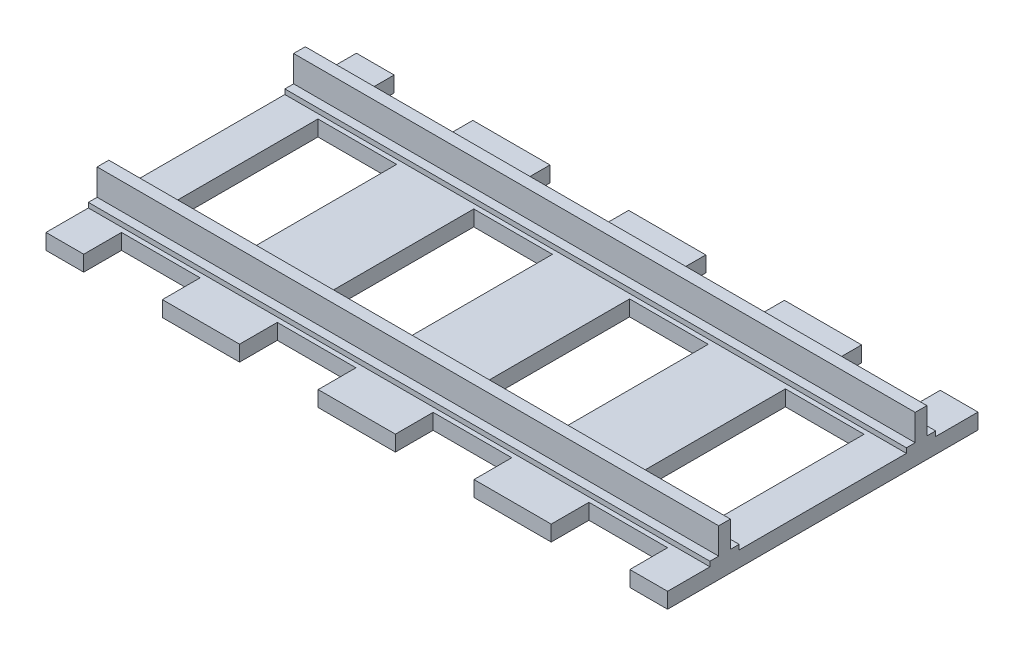
from build123d import *

# Parameters (mm, degrees)
SKETCH1_W           = 7.75
SKETCH1_H           = 32.45
SKETCH1_H_2         = 7.9
SKETCH1_H_3         = 7.75
SKETCH1_W_2         = 16.15
SKETCH1_W_3         = 15.85
BOSS_EXTRUDE1_DEPTH = 3.2
SKETCH2_W           = 127.65
SKETCH2_H           = 6
BOSS_EXTRUDE2_DEPTH = 1
SKETCH3_W           = 127.65
SKETCH3_H           = 2.4
BOSS_EXTRUDE3_DEPTH = 5.4


with BuildPart() as part:
    # Sketch1 → Boss-Extrude1 (new body)
    with BuildSketch(Plane(origin=(0, 0, 0), x_dir=(1, 0, 0), z_dir=(0, 1, 0))):
        with Locations((-59.95, 0)):
            Rectangle(SKETCH1_W, SKETCH1_H)
        with Locations((-59.95, 20.175)):
            Rectangle(SKETCH1_W, SKETCH1_H_2)
        with Locations((-59.95, 28)):
            Rectangle(SKETCH1_W, SKETCH1_H_3)
        with Locations((-59.95, -20.175)):
            Rectangle(SKETCH1_W, SKETCH1_H_2)
        with Locations((-59.95, -28)):
            Rectangle(SKETCH1_W, SKETCH1_H_3)
        with Locations((-48, 20.175)):
            Rectangle(SKETCH1_W_2, SKETCH1_H_2)
        with Locations((-48, -20.175)):
            Rectangle(SKETCH1_W_2, SKETCH1_H_2)
        with Locations((-32, -28)):
            Rectangle(SKETCH1_W_3, SKETCH1_H_3)
        with Locations((-32, -20.175)):
            Rectangle(SKETCH1_W_3, SKETCH1_H_2)
        with Locations((-32, 0)):
            Rectangle(SKETCH1_W_3, SKETCH1_H)
        with Locations((-32, 20.175)):
            Rectangle(SKETCH1_W_3, SKETCH1_H_2)
        with Locations((-32, 28)):
            Rectangle(SKETCH1_W_3, SKETCH1_H_3)
        with Locations((-16, 20.175)):
            Rectangle(SKETCH1_W_2, SKETCH1_H_2)
        with Locations((-16, -20.175)):
            Rectangle(SKETCH1_W_2, SKETCH1_H_2)
        with Locations((0, -20.175)):
            Rectangle(SKETCH1_W_3, SKETCH1_H_2)
        with Locations((0, -28)):
            Rectangle(SKETCH1_W_3, SKETCH1_H_3)
        with Locations((0, 20.175)):
            Rectangle(SKETCH1_W_3, SKETCH1_H_2)
        Rectangle(SKETCH1_W_3, SKETCH1_H)
        with Locations((0, 28)):
            Rectangle(SKETCH1_W_3, SKETCH1_H_3)
        with Locations((32, 28)):
            Rectangle(SKETCH1_W_3, SKETCH1_H_3)
        with Locations((32, 20.175)):
            Rectangle(SKETCH1_W_3, SKETCH1_H_2)
        with Locations((32, 0)):
            Rectangle(SKETCH1_W_3, SKETCH1_H)
        with Locations((32, -20.175)):
            Rectangle(SKETCH1_W_3, SKETCH1_H_2)
        with Locations((32, -28)):
            Rectangle(SKETCH1_W_3, SKETCH1_H_3)
        with Locations((16, 20.175)):
            Rectangle(SKETCH1_W_2, SKETCH1_H_2)
        with Locations((16, -20.175)):
            Rectangle(SKETCH1_W_2, SKETCH1_H_2)
        with Locations((48, -20.175)):
            Rectangle(SKETCH1_W_2, SKETCH1_H_2)
        with Locations((48, 20.175)):
            Rectangle(SKETCH1_W_2, SKETCH1_H_2)
        with Locations((59.95, 28)):
            Rectangle(SKETCH1_W, SKETCH1_H_3)
        with Locations((59.95, 20.175)):
            Rectangle(SKETCH1_W, SKETCH1_H_2)
        with Locations((59.95, 0)):
            Rectangle(SKETCH1_W, SKETCH1_H)
        with Locations((59.95, -20.175)):
            Rectangle(SKETCH1_W, SKETCH1_H_2)
        with Locations((59.95, -28)):
            Rectangle(SKETCH1_W, SKETCH1_H_3)
    extrude(amount=BOSS_EXTRUDE1_DEPTH)

    # Sketch2 → Boss-Extrude2 (add)
    with BuildSketch(Plane(origin=(0, 3.2, 0), x_dir=(1, 0, 0), z_dir=(0, 1, 0))):
        with Locations((0, -20.175)):
            Rectangle(SKETCH2_W, SKETCH2_H)
        with Locations((0, 20.175)):
            Rectangle(SKETCH2_W, SKETCH2_H)
    extrude(amount=BOSS_EXTRUDE2_DEPTH)

    # Sketch3 → Boss-Extrude3 (add)
    with BuildSketch(Plane(origin=(0, 4.2, 0), x_dir=(1, 0, 0), z_dir=(0, 1, 0))):
        with Locations((0, 20.175)):
            Rectangle(SKETCH3_W, SKETCH3_H)
        with Locations((0, -20.175)):
            Rectangle(SKETCH3_W, SKETCH3_H)
    extrude(amount=BOSS_EXTRUDE3_DEPTH)


solid = part.part
